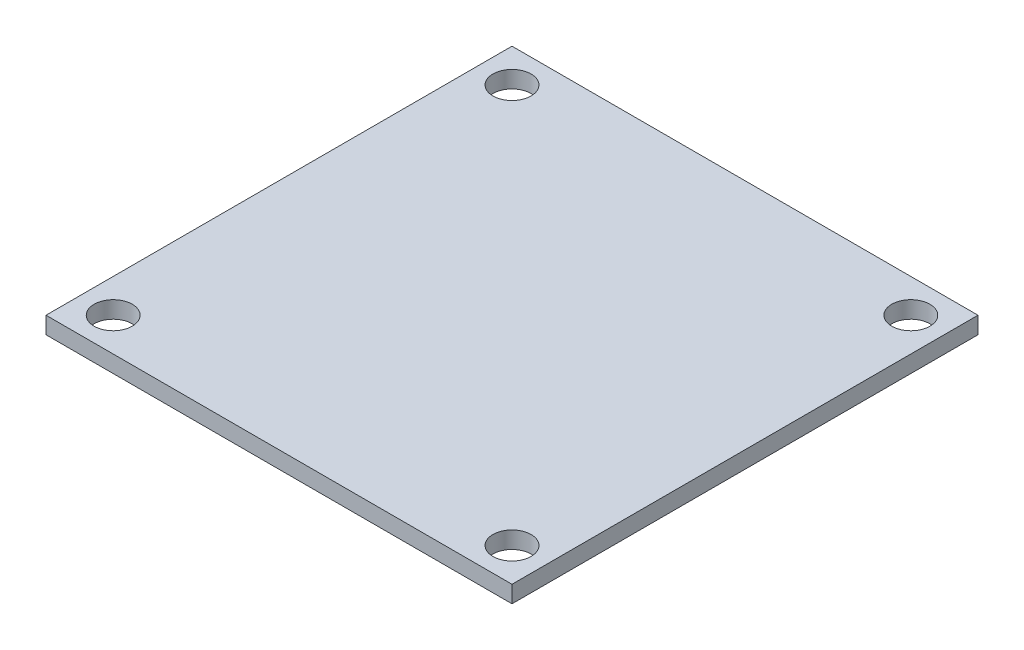
from build123d import *

# Parameters (mm, degrees)
SKETCH2_W           = 55
SKETCH2_H           = 55
BOSS_EXTRUDE1_DEPTH = 2
SKETCH3_R           = 2.25
CUT_EXTRUDE1_DEPTH  = 2


with BuildPart() as part:
    # Sketch2 → Boss-Extrude1 (new body)
    with BuildSketch(Plane(origin=(0, 0, 0), x_dir=(1, 0, 0), z_dir=(0, 1, 0))):
        Rectangle(SKETCH2_W, SKETCH2_H)
    extrude(amount=BOSS_EXTRUDE1_DEPTH)

    # Sketch3 → Cut-Extrude1 (cut)
    with BuildSketch(Plane(origin=(0, 2, 0), x_dir=(1, 0, 0), z_dir=(0, 1, 0))):
        with Locations((23.535533906, -23.535533906)):
            Circle(SKETCH3_R)
        with Locations((-23.535533906, -23.535533906)):
            Circle(SKETCH3_R)
        with Locations((23.535533906, 23.535533906)):
            Circle(SKETCH3_R)
        with Locations((-23.535533906, 23.535533906)):
            Circle(SKETCH3_R)
    extrude(amount=-CUT_EXTRUDE1_DEPTH, mode=Mode.SUBTRACT)


solid = part.part
